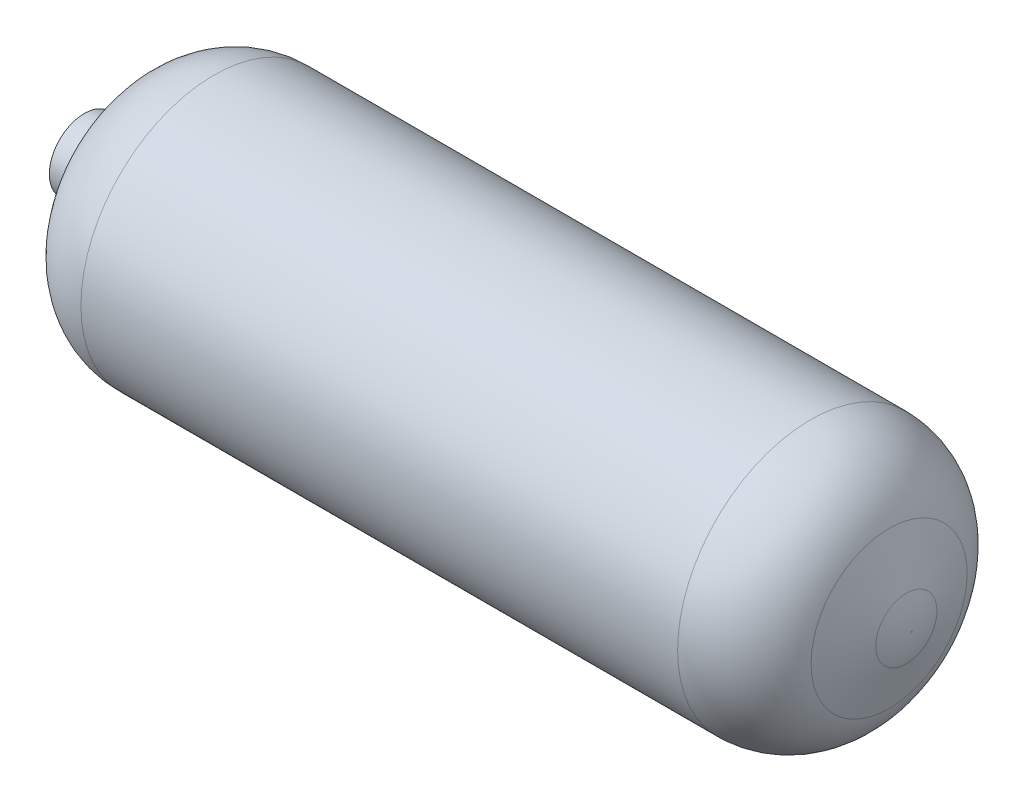
from build123d import *

# Parameters (mm, degrees)
SCALE1_SCALE = 649.76746201
SHELL2_T     = 5.588


with BuildPart() as part:
    # Sketch1 → Revolve2 (revolve)
    with BuildSketch(Plane.XY):
        with BuildLine():
            Line((0.30325, 0.129), (-0.275595218, 0.129))
            ThreePointArc((-0.275595218, 0.129), (-0.3184401, 0.116916493), (-0.348657753, 0.084227221))
            Line((-0.348657753, 0.084227221), (-0.372858421, 0.036730735))
            ThreePointArc((-0.372858421, 0.036730735), (-0.374701425, 0.034736985), (-0.377314576, 0.034))
            Line((-0.377314576, 0.034), (-0.40125, 0.034))
            Line((-0.40125, 0.034), (-0.40125, 0))
            Line((-0.40125, 0), (0.40125, 0))
            Line((0.40125, 0), (0.40125, 0.000587576))
            ThreePointArc((0.40125, 0.000587576), (0.399958659, 0.015347671), (0.396123873, 0.029659288))
            Line((0.396123873, 0.029659288), (0.379365102, 0.075703632))
            ThreePointArc((0.379365102, 0.075703632), (0.349709691, 0.114351316), (0.30325, 0.129))
        make_face()
    revolve(axis=Axis((-0.40125, 0, 0), (1, 0, 0)))


with BuildPart() as part_1:
    # Scale1: scaled about (0, 0, 0)
    add(part.part.scale(SCALE1_SCALE))

    # Shell2 (no face opened: a closed hollow body)
    add(offset(amount=-SHELL2_T, mode=Mode.PRIVATE), mode=Mode.SUBTRACT)


solid = part_1.part
